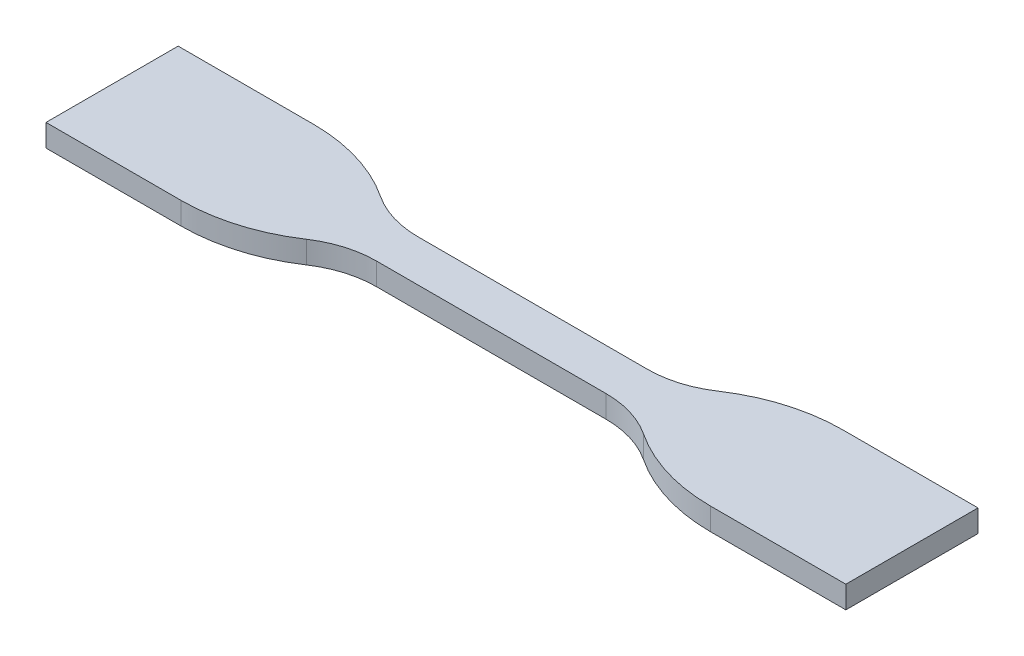
from build123d import *

# Parameters (mm, degrees)
SALIENTE_EXTRUIR2_DEPTH = 3.2


with BuildPart() as part:
    # Croquis1 → Saliente-Extruir2 (new body)
    with BuildSketch(Plane(origin=(0, 0, 0), x_dir=(1, 0, 0), z_dir=(0, 1, 0))):
        with BuildLine():
            Line((-16.5, 3), (16.5, 3))
            ThreePointArc((16.5, 3), (20.541451884, 3.596020491), (24.238791177, 5.333333333))
            ThreePointArc((24.238791177, 5.333333333), (30.841182772, 8.435677694), (38.058061137, 9.5))
            Line((38.058061137, 9.5), (57.5, 9.5))
            Line((57.5, 9.5), (57.5, -9.5))
            Line((57.5, -9.5), (38.058061137, -9.5))
            ThreePointArc((38.058061137, -9.5), (30.841182772, -8.435677694), (24.238791177, -5.333333333))
            ThreePointArc((24.238791177, -5.333333333), (20.541451884, -3.596020491), (16.5, -3))
            Line((16.5, -3), (-16.5, -3))
            ThreePointArc((-16.5, -3), (-20.541451884, -3.596020491), (-24.238791177, -5.333333333))
            ThreePointArc((-24.238791177, -5.333333333), (-30.841182772, -8.435677694), (-38.058061137, -9.5))
            Line((-38.058061137, -9.5), (-57.5, -9.5))
            Line((-57.5, -9.5), (-57.5, 9.5))
            Line((-57.5, 9.5), (-38.058061137, 9.5))
            ThreePointArc((-38.058061137, 9.5), (-30.841182772, 8.435677694), (-24.238791177, 5.333333333))
            ThreePointArc((-24.238791177, 5.333333333), (-20.541451884, 3.596020491), (-16.5, 3))
        make_face()
    extrude(amount=SALIENTE_EXTRUIR2_DEPTH)


solid = part.part
